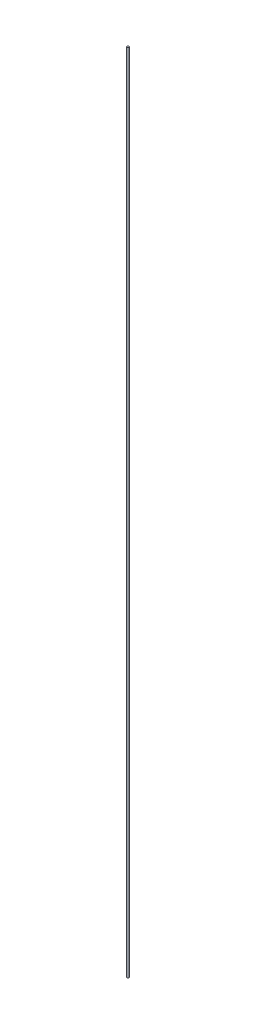
from build123d import *

# Parameters (mm, degrees)
SKETCH1_R           = 1.27
BOSS_EXTRUDE1_DEPTH = 990.6


with BuildPart() as part:
    # Sketch1 → Boss-Extrude1 (new body)
    with BuildSketch(Plane(origin=(0, 0, 0), x_dir=(1, 0, 0), z_dir=(0, 1, 0))):
        Circle(SKETCH1_R)
    extrude(amount=BOSS_EXTRUDE1_DEPTH)


solid = part.part
